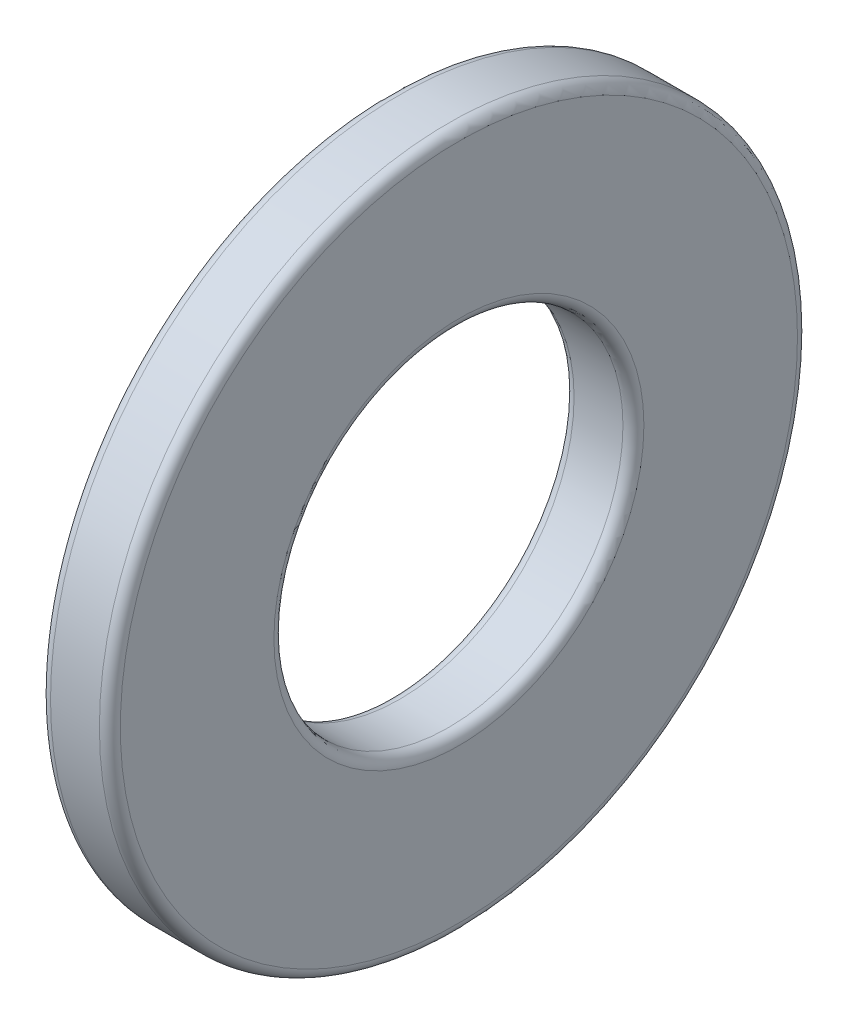
from build123d import *

# Parameters (mm, degrees)
SKETCH1_R           = 5
SKETCH1_R_2         = 2.5
BOSS_EXTRUDE1_DEPTH = 1
FILLET1_R           = 0.15


with BuildPart() as part:
    # Sketch1 → Boss-Extrude1 (new body)
    with BuildSketch(Plane(origin=(0, 0, 0), x_dir=(0, 0, -1), z_dir=(1, 0, 0))):
        Circle(SKETCH1_R)
        Circle(SKETCH1_R_2, mode=Mode.SUBTRACT)
    extrude(amount=BOSS_EXTRUDE1_DEPTH)

    # Fillet1
    fillet1_edges = [part.edges().sort_by_distance(p)[0] for p in [
        (0, 0, 5),
        (1, 0, 5),
        (0, 0, 2.5),
        (1, 0, 2.5),
    ]]
    fillet(fillet1_edges, radius=FILLET1_R)


solid = part.part
